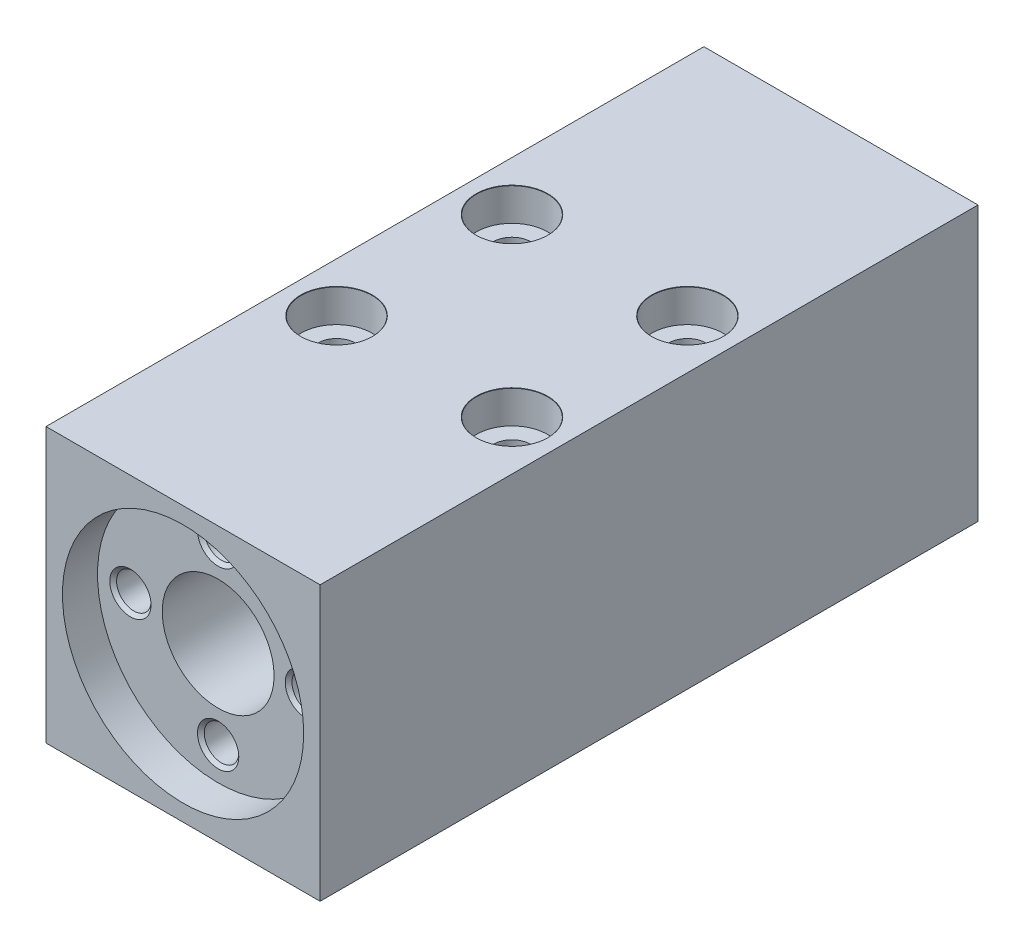
from build123d import *

# Parameters (mm, degrees)
ESBO_O1_W                                         = 25
ESBO_O1_H                                         = 25
RESSALTO_EXTRUS_O1_DEPTH                          = 60
ESBO_O2_R                                         = 5.1
CORTE_EXTRUS_O1_DEPTH                             = 61
ESBO_O3_R                                         = 11
CORTE_EXTRUS_O2_DEPTH                             = 3.2
FURO_ROSCADO_PARA_CONDU_TE_DE_M3X0_51_D           = 3.15
FURO_ROSCADO_PARA_CONDU_TE_DE_M3X0_51_DEPTH       = 6
FURO_ROSCADO_PARA_CONDU_TE_DE_M3X0_51_CSINK_D     = 3.766
FURO_ROSCADO_PARA_CONDU_TE_DE_M3X0_51_CSINK_ANGLE = 90
FURO_ROSCADO_PARA_CONDU_TE_DE_M3X0_51_TIP         = 0.946355475
REBAIXO_PARA_SHCS_M31_AT_2_COUNT                  = 2
REBAIXO_PARA_SHCS_M31_AT_2_PITCH                  = 16
REBAIXO_PARA_SHCS_M31_AT_3_COUNT                  = 2
REBAIXO_PARA_SHCS_M31_AT_3_PITCH                  = 16
REBAIXO_PARA_SHCS_M31_AT_4_COUNT                  = 2
REBAIXO_PARA_SHCS_M31_AT_4_PITCH                  = 22.627416998


with BuildPart() as part:
    # Esboço1 → Ressalto-extrusão1 (new body)
    with BuildSketch(Plane.XY):
        Rectangle(ESBO_O1_W, ESBO_O1_H)
    extrude(amount=RESSALTO_EXTRUS_O1_DEPTH)

    # Esboço2 → Corte-extrusão1 (cut, through all)
    with BuildSketch(Plane.XY.offset(60)):
        Circle(ESBO_O2_R)
    extrude(amount=-CORTE_EXTRUS_O1_DEPTH, mode=Mode.SUBTRACT)

    # Esboço3 → Corte-extrusão2 (cut)
    with BuildSketch(Plane.XY.offset(60)):
        Circle(ESBO_O3_R)
    extrude(amount=-CORTE_EXTRUS_O2_DEPTH, mode=Mode.SUBTRACT)

    # Furo roscado para conduíte de M3x0.51
    with Locations(Plane.XY.offset(56.8)):
        with Locations((0, 8), (8, 0), (0, -8), (-8, 0)):
            CounterSinkHole(FURO_ROSCADO_PARA_CONDU_TE_DE_M3X0_51_D / 2, FURO_ROSCADO_PARA_CONDU_TE_DE_M3X0_51_CSINK_D / 2, depth=FURO_ROSCADO_PARA_CONDU_TE_DE_M3X0_51_DEPTH, counter_sink_angle=FURO_ROSCADO_PARA_CONDU_TE_DE_M3X0_51_CSINK_ANGLE)
            with Locations((0, 0, -(FURO_ROSCADO_PARA_CONDU_TE_DE_M3X0_51_DEPTH + FURO_ROSCADO_PARA_CONDU_TE_DE_M3X0_51_TIP / 2))):  # 118° drill point
                Cone(0, FURO_ROSCADO_PARA_CONDU_TE_DE_M3X0_51_D / 2, FURO_ROSCADO_PARA_CONDU_TE_DE_M3X0_51_TIP, mode=Mode.SUBTRACT)

    # Esboço7 → Rebaixo para SHCS M31 (revolve, cut)
    with BuildSketch(Plane(origin=(-8, 12.5, 22), x_dir=(0, 0, 1), z_dir=(1, 0, 0))):
        Polygon((0, 0), (0, 25), (1.7, 25), (1.7, 3), (3.25, 3), (3.25, 0.025), (3.275, 0), align=None)
    rebaixo_para_shcs_m31 = revolve(axis=Axis((-8, 18.85, 22), (0, -1, 0)), mode=Mode.SUBTRACT)

    # Rebaixo para SHCS M31 at 2: Rebaixo para SHCS M31 ×2
    with Locations(*[(i * REBAIXO_PARA_SHCS_M31_AT_2_PITCH, 0, 0) for i in range(1, REBAIXO_PARA_SHCS_M31_AT_2_COUNT)]):
        add(rebaixo_para_shcs_m31, mode=Mode.SUBTRACT)

    # Rebaixo para SHCS M31 at 3: Rebaixo para SHCS M31 ×2
    with Locations(*[(0, 0, i * REBAIXO_PARA_SHCS_M31_AT_3_PITCH) for i in range(1, REBAIXO_PARA_SHCS_M31_AT_3_COUNT)]):
        add(rebaixo_para_shcs_m31, mode=Mode.SUBTRACT)

    # Rebaixo para SHCS M31 at 4: Rebaixo para SHCS M31 ×2
    with Locations(*[Vector(0.707106781, 0, 0.707106781) * (i * REBAIXO_PARA_SHCS_M31_AT_4_PITCH) for i in range(1, REBAIXO_PARA_SHCS_M31_AT_4_COUNT)]):
        add(rebaixo_para_shcs_m31, mode=Mode.SUBTRACT)


solid = part.part
